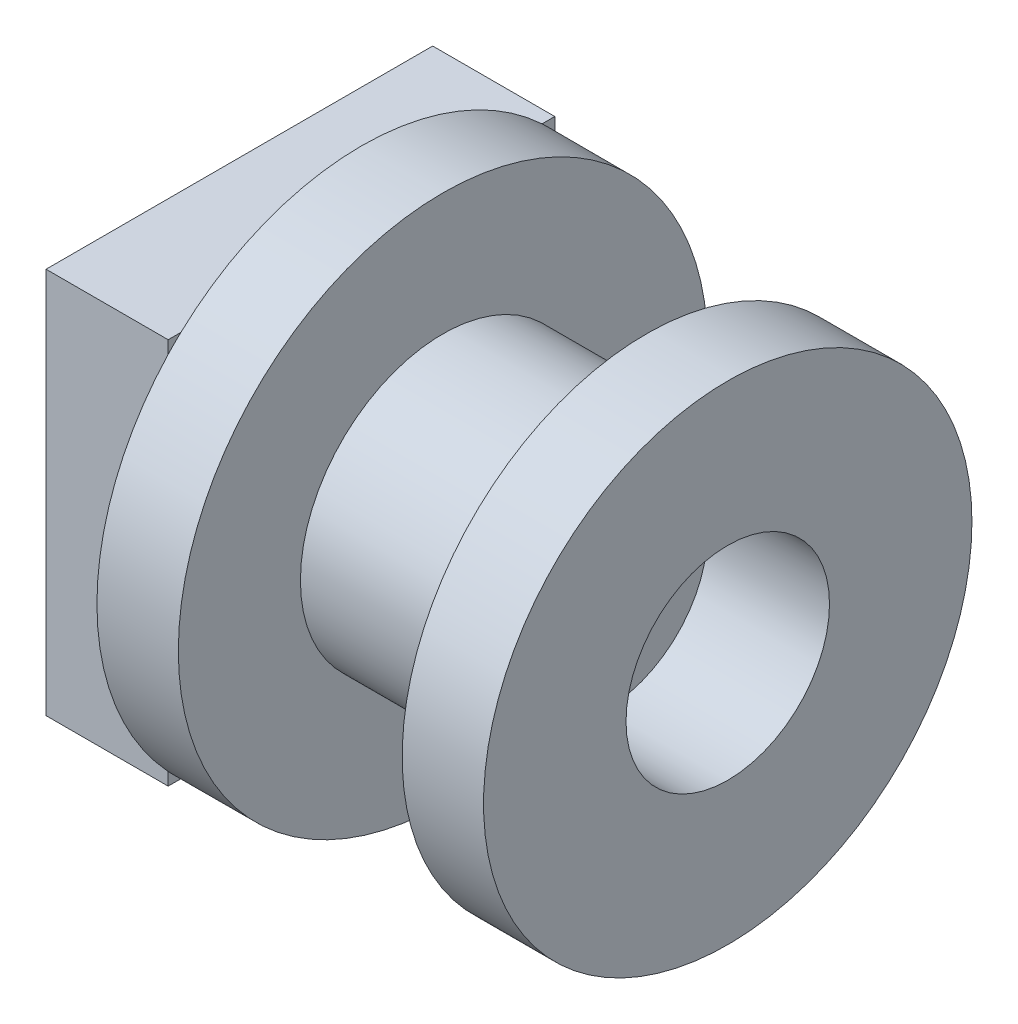
from build123d import *

# Parameters (mm, degrees)
SKETCH1_W           = 3
SKETCH1_H           = 3
BOSS_EXTRUDE1_DEPTH = 4
SKETCH2_W           = 19
SKETCH2_H           = 19
BOSS_EXTRUDE2_DEPTH = 6
SKETCH3_R           = 13
BOSS_EXTRUDE3_DEPTH = 4
SKETCH4_R           = 7
BOSS_EXTRUDE4_DEPTH = 10
SKETCH5_R           = 12
BOSS_EXTRUDE5_DEPTH = 4
SKETCH6_R           = 5
CUT_EXTRUDE1_DEPTH  = 6


with BuildPart() as part:
    # Sketch1 → Boss-Extrude1 (new body)
    with BuildSketch(Plane(origin=(0, 0, 0), x_dir=(0, 0, -1), z_dir=(1, 0, 0))):
        Rectangle(SKETCH1_W, SKETCH1_H)
    extrude(amount=BOSS_EXTRUDE1_DEPTH)

    # Sketch2 → Boss-Extrude2 (add)
    with BuildSketch(Plane(origin=(4, 0, 0), x_dir=(0, 0, -1), z_dir=(1, 0, 0))):
        Rectangle(SKETCH2_W, SKETCH2_H)
    extrude(amount=BOSS_EXTRUDE2_DEPTH)

    # Sketch3 → Boss-Extrude3 (add)
    with BuildSketch(Plane(origin=(10, 0, 0), x_dir=(0, 0, -1), z_dir=(1, 0, 0))):
        Circle(SKETCH3_R)
    extrude(amount=BOSS_EXTRUDE3_DEPTH)

    # Sketch4 → Boss-Extrude4 (add)
    with BuildSketch(Plane(origin=(14, 0, 0), x_dir=(0, 0, -1), z_dir=(1, 0, 0))):
        Circle(SKETCH4_R)
    extrude(amount=BOSS_EXTRUDE4_DEPTH)

    # Sketch5 → Boss-Extrude5 (add)
    with BuildSketch(Plane(origin=(24, 0, 0), x_dir=(0, 0, -1), z_dir=(1, 0, 0))):
        Circle(SKETCH5_R)
    extrude(amount=BOSS_EXTRUDE5_DEPTH)

    # Sketch6 → Cut-Extrude1 (cut)
    with BuildSketch(Plane(origin=(28, 0, 0), x_dir=(0, 0, -1), z_dir=(1, 0, 0))):
        Circle(SKETCH6_R)
    extrude(amount=-CUT_EXTRUDE1_DEPTH, mode=Mode.SUBTRACT)


solid = part.part
